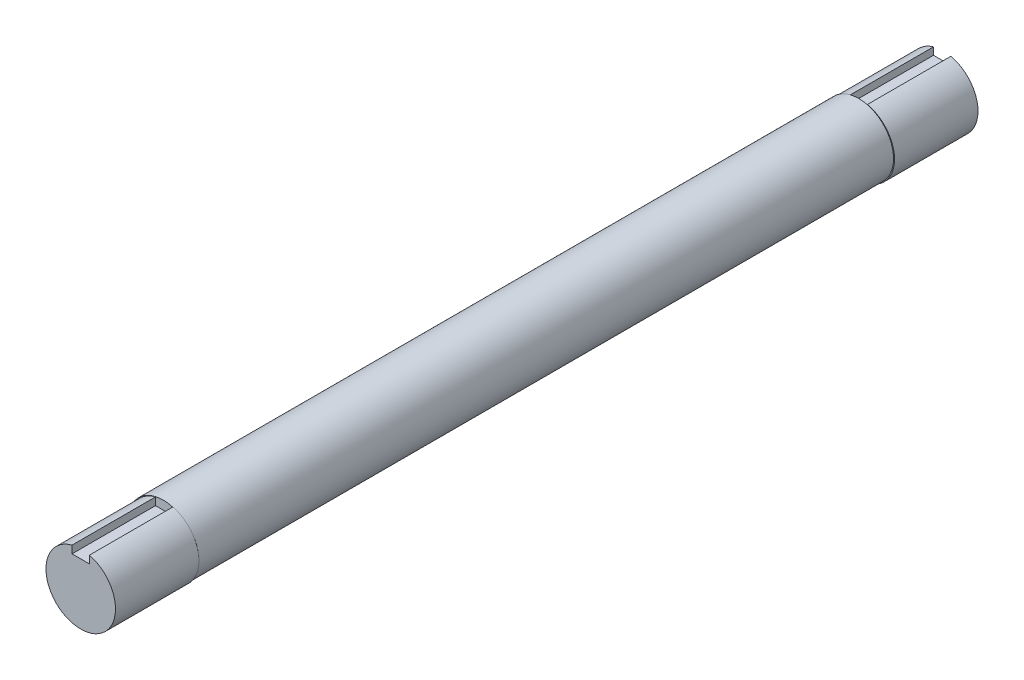
from build123d import *

# Parameters (mm, degrees)
SKETCH2_R           = 127
BOSS_EXTRUDE1_DEPTH = 2540
BOSS_EXTRUDE2_DEPTH = 304.8
BOSS_EXTRUDE3_DEPTH = 304.8


with BuildPart() as part:
    # Sketch2 → Boss-Extrude1 (new body)
    with BuildSketch(Plane.XY):
        with Locations((-3.698748578, 0)):
            Circle(SKETCH2_R)
    extrude(amount=BOSS_EXTRUDE1_DEPTH)

    # Sketch4 → Boss-Extrude2 (add)
    with BuildSketch(Plane.XY.offset(2540)):
        with BuildLine():
            Line((-31.75, 122.911581061), (-31.75, 95.196127389))
            Line((-31.75, 95.196127389), (31.75, 95.196127389))
            Line((31.75, 95.196127389), (31.75, 122.911581061))
            ThreePointArc((31.75, 122.911581061), (0, -126.946127389), (-31.75, 122.911581061))
        make_face()
    extrude(amount=BOSS_EXTRUDE2_DEPTH)

    # Sketch5 → Boss-Extrude3 (add)
    with BuildSketch(Plane(origin=(0, 0, 0), x_dir=(-1, 0, 0), z_dir=(0, 0, -1))):
        with BuildLine():
            Line((-28.051251422, 123.918554037), (-28.051251422, 95.25))
            Line((-28.051251422, 95.25), (35.448748578, 95.25))
            Line((35.448748578, 95.25), (35.448748578, 122.008470875))
            ThreePointArc((35.448748578, 122.008470875), (-3.820058306, -126.996408987), (-28.051251422, 123.918554037))
        make_face()
    extrude(amount=BOSS_EXTRUDE3_DEPTH)


solid = part.part
